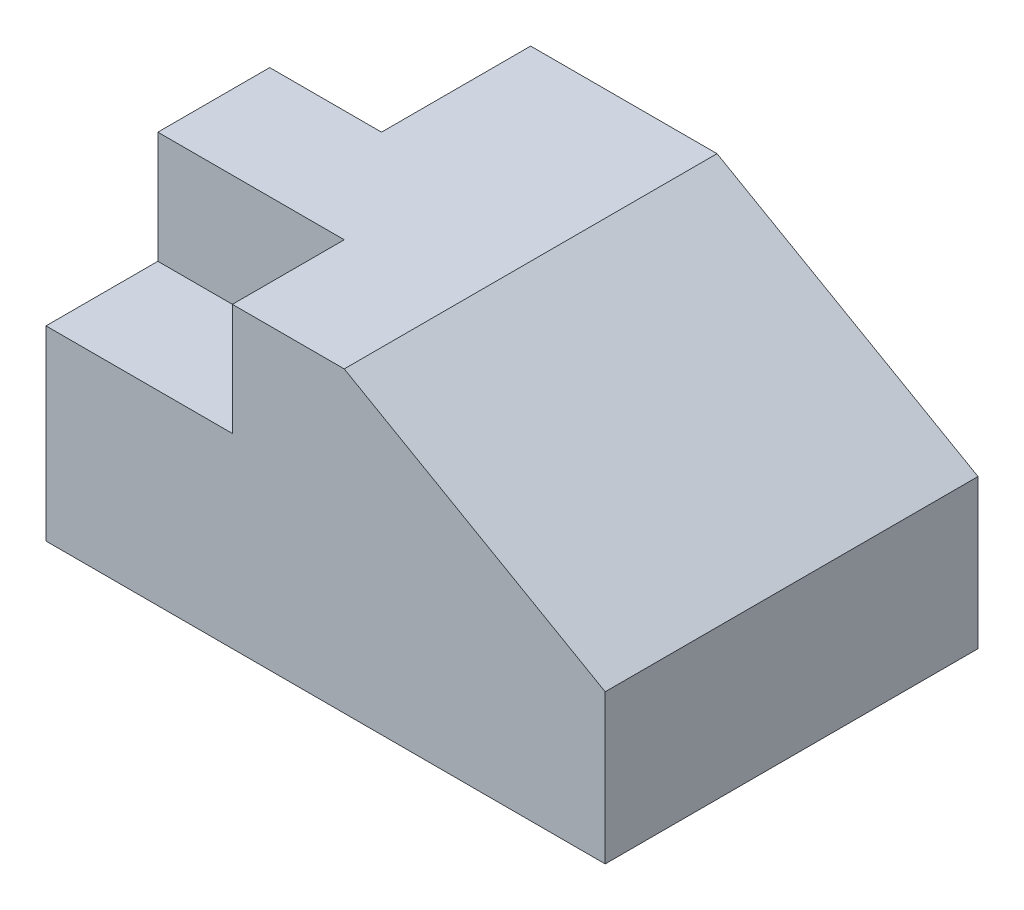
from build123d import *

# Parameters (mm, degrees)
BOSS_EXTRUDE1_DEPTH = 100
SKETCH1_3_W         = 50
SKETCH1_3_H         = 30
CUT_EXTRUDE1_DEPTH  = 30
SKETCH3_W           = 30
SKETCH3_H           = 40
CUT_EXTRUDE2_DEPTH  = 30


with BuildPart() as part:
    # Sketch1 → Boss-Extrude1 (new body)
    with BuildSketch(Plane.XY):
        Polygon((-75, 40), (-75, -40), (75, -40), (75, 0), (5, 40), align=None)
    extrude(amount=-BOSS_EXTRUDE1_DEPTH)

    # Sketch1_3 → Cut-Extrude1 (cut)
    with BuildSketch(Plane.XY):
        with Locations((-50, 25)):
            Rectangle(SKETCH1_3_W, SKETCH1_3_H)
    extrude(amount=-CUT_EXTRUDE1_DEPTH, mode=Mode.SUBTRACT)

    # Sketch3 → Cut-Extrude2 (cut)
    with BuildSketch(Plane(origin=(0, 40, 0), x_dir=(1, 0, 0), z_dir=(0, 1, 0))):
        with Locations((-60, 80)):
            Rectangle(SKETCH3_W, SKETCH3_H)
    extrude(amount=-CUT_EXTRUDE2_DEPTH, mode=Mode.SUBTRACT)


solid = part.part
